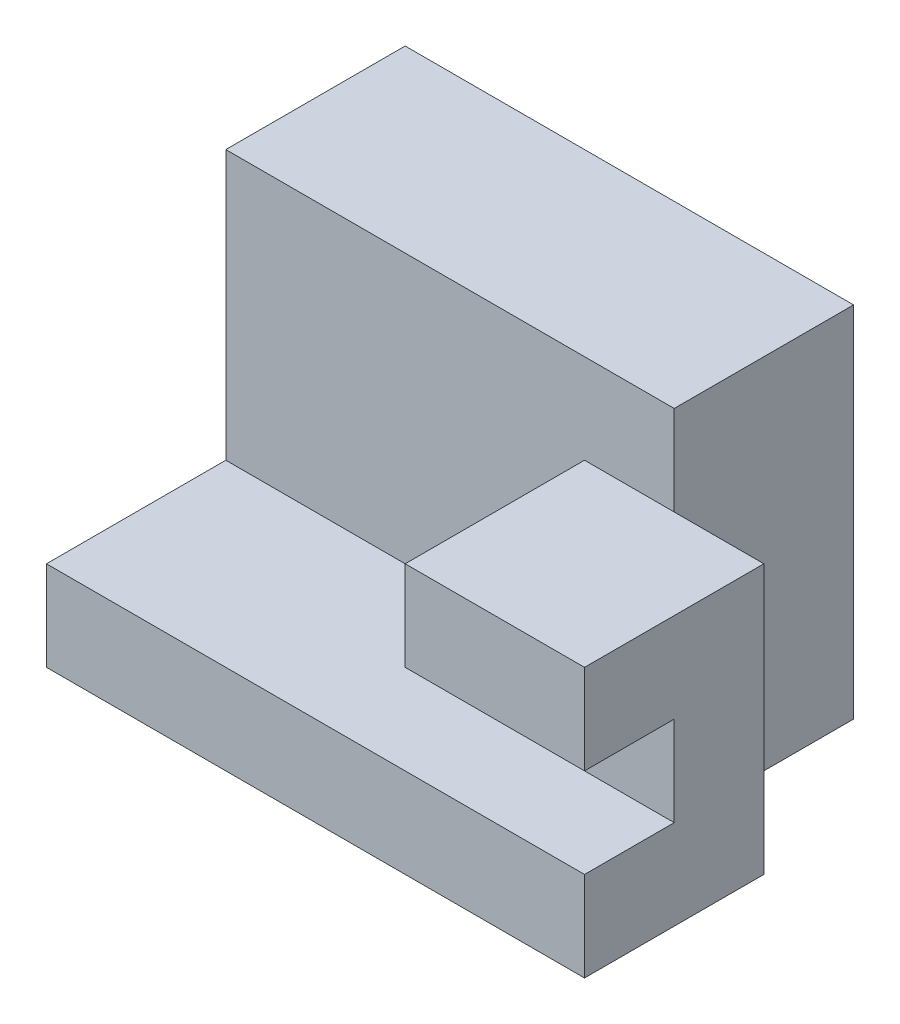
from build123d import *

# Parameters (mm, degrees)
SKETCH1_W           = 1016
SKETCH1_H           = 508
BOSS_EXTRUDE1_DEPTH = 254
BOSS_EXTRUDE2_DEPTH = 1016
BOSS_EXTRUDE3_DEPTH = 762
SKETCH2_W           = 254
SKETCH2_H           = 254
CUT_EXTRUDE3_DEPTH  = 508


with BuildPart() as part:
    # Sketch1 → Boss-Extrude1 (new body)
    with BuildSketch(Plane(origin=(0, 0, 0), x_dir=(1, 0, 0), z_dir=(0, 1, 0))):
        with Locations((508, 254)):
            Rectangle(SKETCH1_W, SKETCH1_H)
    extrude(amount=BOSS_EXTRUDE1_DEPTH)

    # Sketch1_3 → Boss-Extrude2 (add)
    with BuildSketch(Plane(origin=(0, 0, 0), x_dir=(1, 0, 0), z_dir=(0, 1, 0))):
        Polygon((0, 1016), (0, 508), (1016, 508), (1270, 508), (1270, 1016), align=None)
    extrude(amount=BOSS_EXTRUDE2_DEPTH)

    # Sketch1_4 → Boss-Extrude3 (add)
    with BuildSketch(Plane(origin=(0, 0, 0), x_dir=(1, 0, 0), z_dir=(0, 1, 0))):
        Polygon((1016, 508), (1016, 0), (1524, 0), (1524, 508), (1270, 508), align=None)
    extrude(amount=BOSS_EXTRUDE3_DEPTH)

    # Sketch2 → Cut-Extrude3 (cut)
    with BuildSketch(Plane.ZY.offset(-1016)):
        with Locations((-127, 381)):
            Rectangle(SKETCH2_W, SKETCH2_H)
    extrude(amount=-CUT_EXTRUDE3_DEPTH, mode=Mode.SUBTRACT)


solid = part.part
